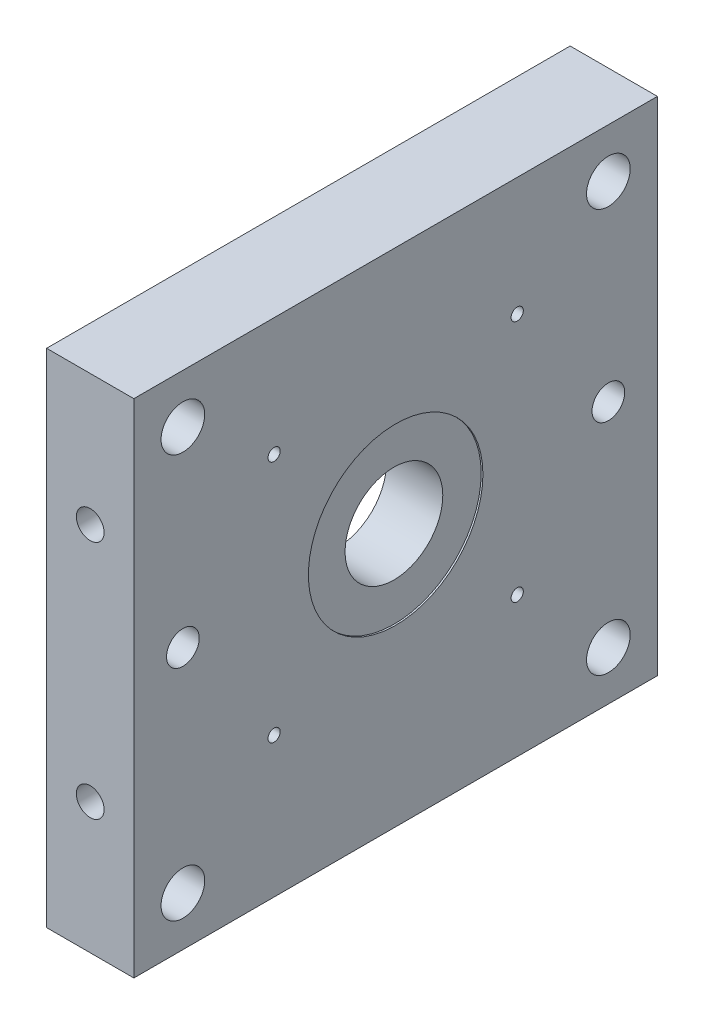
from build123d import *

# Parameters (mm, degrees)
SKETCH1_W          = 76.2
SKETCH1_H          = 73.025
EXTRUDE1_DEPTH     = 12.7
SKETCH8_R          = 0.889
SKETCH8_R_2        = 3.175
SKETCH8_R_3        = 7.112
SKETCH8_R_4        = 2.38125
CUT_EXTRUDE5_DEPTH = 12.7
SKETCH11_R         = 5.207
CUT_EXTRUDE6_DEPTH = 6.35
SKETCH13_R         = 17.4625
CUT_EXTRUDE7_DEPTH = 4.2545
SKETCH14_R         = 12.7
CUT_EXTRUDE8_DEPTH = 0.254
SKETCH15_R         = 2.0193
CUT_EXTRUDE9_DEPTH = 77.2


with BuildPart() as part:
    # Sketch1 → Extrude1 (new body)
    with BuildSketch(Plane(origin=(0, 0, 0), x_dir=(0, 0, -1), z_dir=(1, 0, 0))):
        with Locations((38.1, -36.5125)):
            Rectangle(SKETCH1_W, SKETCH1_H)
    extrude(amount=EXTRUDE1_DEPTH)

    # Sketch8 → Cut-Extrude5 (cut)
    with BuildSketch(Plane.ZY):
        with Locations((-55.796122625, -17.233895441)):
            Circle(SKETCH8_R)
        with Locations((-7.1374, -7.1374)):
            Circle(SKETCH8_R_2)
        with Locations((-69.0626, -7.1374)):
            Circle(SKETCH8_R_2)
        with Locations((-69.0626, -65.8876)):
            Circle(SKETCH8_R_2)
        with Locations((-7.1374, -65.8876)):
            Circle(SKETCH8_R_2)
        with Locations((-38.105018066, -34.925)):
            Circle(SKETCH8_R_3)
        with Locations((-69.0626, -34.925)):
            Circle(SKETCH8_R_4)
        with Locations((-7.1374, -34.925)):
            Circle(SKETCH8_R_4)
        with Locations((-20.413913508, -17.233895441)):
            Circle(SKETCH8_R)
        with Locations((-55.796122625, -52.616104559)):
            Circle(SKETCH8_R)
        with Locations((-20.413913508, -52.616104559)):
            Circle(SKETCH8_R)
    extrude(amount=-CUT_EXTRUDE5_DEPTH, mode=Mode.SUBTRACT)

    # Sketch11 → Cut-Extrude6 (cut)
    with BuildSketch(Plane.ZY):
        with Locations((-7.1374, -7.1374)):
            Circle(SKETCH11_R)
        with Locations((-69.0626, -7.1374)):
            Circle(SKETCH11_R)
        with Locations((-69.0626, -65.8876)):
            Circle(SKETCH11_R)
        with Locations((-7.1374, -65.8876)):
            Circle(SKETCH11_R)
    extrude(amount=-CUT_EXTRUDE6_DEPTH, mode=Mode.SUBTRACT)

    # Sketch13 → Cut-Extrude7 (cut)
    with BuildSketch(Plane.ZY):
        with Locations((-38.105018066, -34.925)):
            Circle(SKETCH13_R)
    extrude(amount=-CUT_EXTRUDE7_DEPTH, mode=Mode.SUBTRACT)

    # Sketch14 → Cut-Extrude8 (cut)
    with BuildSketch(Plane(origin=(12.7, 0, 0), x_dir=(0, 0, -1), z_dir=(1, 0, 0))):
        with Locations((38.105018066, -34.925)):
            Circle(SKETCH14_R)
    extrude(amount=-CUT_EXTRUDE8_DEPTH, mode=Mode.SUBTRACT)

    # Sketch15 → Cut-Extrude9 (cut, through all)
    with BuildSketch(Plane(origin=(0, 0, 0), x_dir=(-1, 0, 0), z_dir=(0, 0, -1))):
        with Locations((-6.35, -19.05)):
            Circle(SKETCH15_R)
        with Locations((-6.35, -53.975)):
            Circle(SKETCH15_R)
    extrude(amount=CUT_EXTRUDE9_DEPTH, mode=Mode.SUBTRACT)


solid = part.part
